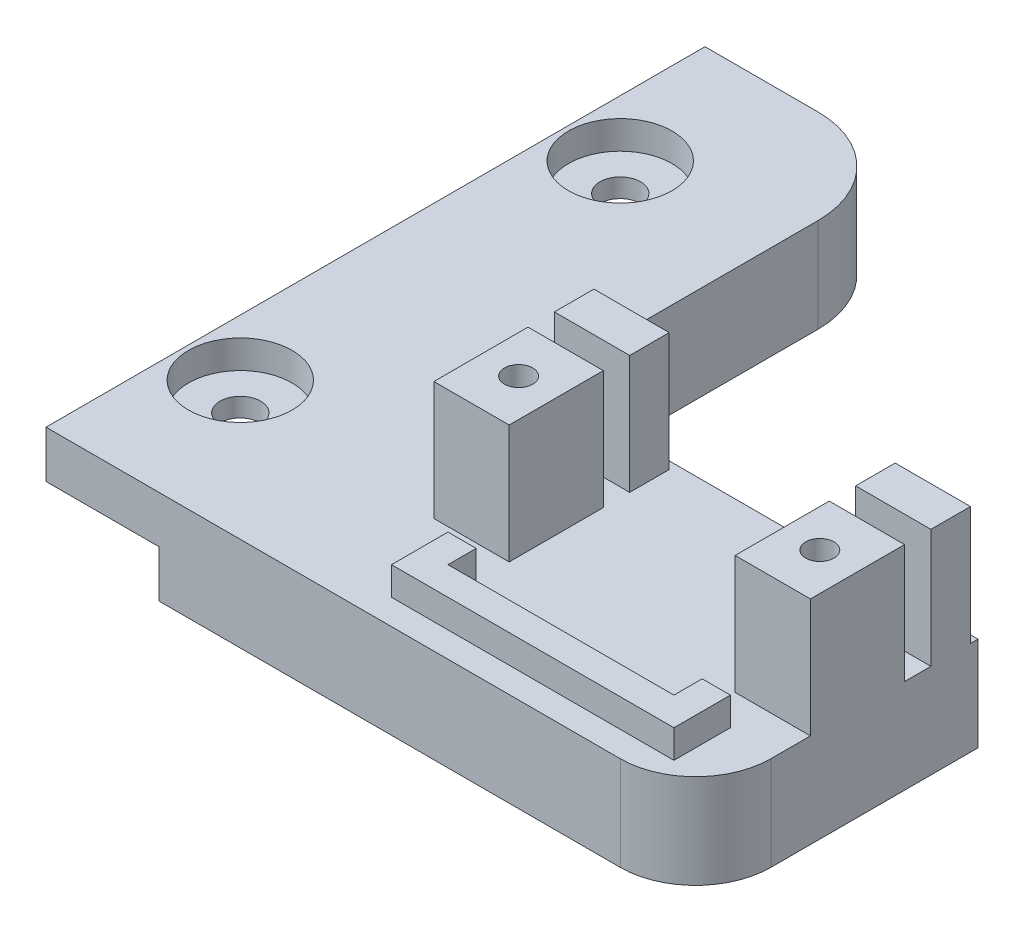
from build123d import *

# Parameters (mm, degrees)
SKETCH1_W                                       = 47
SKETCH1_H                                       = 30
BOSS_STRUCTURE_DEPTH                            = 10
SKETCH2_W                                       = 70
SKETCH2_H                                       = 5
BOSS_ATTACHE_DEPTH                              = 12
SERVO_W                                         = 8
SERVO_H                                         = 4.2
SERVO_H_2                                       = 10
BOSS_SERVO_1_DEPTH                              = 12.6
BOSS_SERVO_2_DEPTH                              = 3
FILLET1_R                                       = 10
FILLET2_R                                       = 8
SKETCH4_R                                       = 1.5
CUT_EXTRUDE1_DEPTH                              = 6
CBORE_FOR_6_PAN_HEAD_MACHINE_SCREW1_D           = 4.3053
CBORE_FOR_6_PAN_HEAD_MACHINE_SCREW1_DEPTH       = 5
CBORE_FOR_6_PAN_HEAD_MACHINE_SCREW1_CBORE_D     = 11.000000098
CBORE_FOR_6_PAN_HEAD_MACHINE_SCREW1_CBORE_DEPTH = 3.000000096


with BuildPart() as part:
    # Sketch1 → Boss-Structure (new body)
    with BuildSketch(Plane(origin=(0, 0, 0), x_dir=(1, 0, 0), z_dir=(0, 1, 0))):
        Polygon((0, 35), (-10, 35), (-10, -35), (0, -35), (0, -5), align=None)
        with Locations((23.5, -20)):
            Rectangle(SKETCH1_W, SKETCH1_H)
    extrude(amount=-BOSS_STRUCTURE_DEPTH)

    # Sketch2 → Boss-Attache (add)
    with BuildSketch(Plane.ZY.offset(10)):
        with Locations((0, -2.5)):
            Rectangle(SKETCH2_W, SKETCH2_H)
    extrude(amount=BOSS_ATTACHE_DEPTH)

    # Servo → Boss-Servo_1 (add)
    with BuildSketch(Plane(origin=(0, 0, 0), x_dir=(1, 0, 0), z_dir=(0, 1, 0))):
        with Locations((11, -7.9)):
            Rectangle(SERVO_W, SERVO_H)
        with Locations((11, -17.8)):
            Rectangle(SERVO_W, SERVO_H_2)
        with Locations((43, -17.8)):
            Rectangle(SERVO_W, SERVO_H_2)
        with Locations((43, -7.9)):
            Rectangle(SERVO_W, SERVO_H)
    extrude(amount=BOSS_SERVO_1_DEPTH)

    # Sketch3_3 → Boss-Servo_2 (add)
    with BuildSketch(Plane(origin=(0, 0, 0), x_dir=(1, 0, 0), z_dir=(0, 1, 0))):
        Polygon((15, -29.3), (15, -26.3), (12, -26.3), (12, -32.3), (27, -32.3), (27, -29.3), align=None)
        Polygon((42, -26.3), (39, -26.3), (39, -29.3), (27, -29.3), (27, -32.3), (42, -32.3), align=None)
    extrude(amount=BOSS_SERVO_2_DEPTH)

    # Fillet1
    fillet1_edges = [part.edges().sort_by_distance(p)[0] for p in [
        (0, -5, -35),
    ]]
    fillet(fillet1_edges, radius=FILLET1_R)

    # Fillet2
    fillet2_edges = [part.edges().sort_by_distance(p)[0] for p in [
        (47, -5, 35),
    ]]
    fillet(fillet2_edges, radius=FILLET2_R)

    # Sketch4 → Cut-Extrude1 (cut)
    with BuildSketch(Plane(origin=(0, 12.6, 0), x_dir=(1, 0, 0), z_dir=(0, 1, 0))):
        with Locations((11, -17.8)):
            Circle(SKETCH4_R)
        with Locations((43, -17.8)):
            Circle(SKETCH4_R)
    extrude(amount=-CUT_EXTRUDE1_DEPTH, mode=Mode.SUBTRACT)

    # CBORE for _6 Pan Head Machine Screw1
    with Locations(Plane(origin=(0, 0, 0), x_dir=(1, 0, 0), z_dir=(0, 1, 0))):
        with Locations((-16, 20), (-16, -20.361423436)):
            CounterBoreHole(CBORE_FOR_6_PAN_HEAD_MACHINE_SCREW1_D / 2, CBORE_FOR_6_PAN_HEAD_MACHINE_SCREW1_CBORE_D / 2, CBORE_FOR_6_PAN_HEAD_MACHINE_SCREW1_CBORE_DEPTH, depth=CBORE_FOR_6_PAN_HEAD_MACHINE_SCREW1_DEPTH)


solid = part.part
